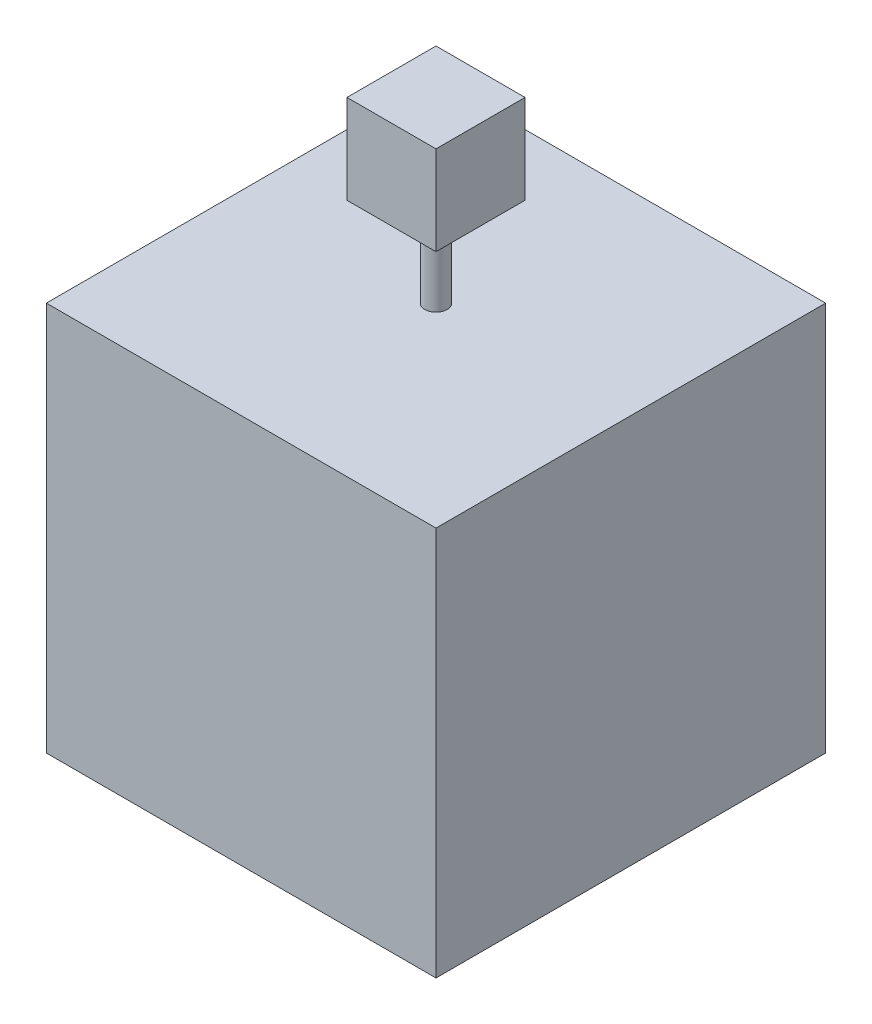
from build123d import *

# Parameters (mm, degrees)
ESQUISSE1_W      = 350
ESQUISSE1_H      = 350
EXTRUSION1_DEPTH = 350
ESQUISSE2_R      = 10
EXTRUSION2_DEPTH = 80
ESQUISSE3_W      = 80
ESQUISSE3_H      = 80
EXTRUSION3_DEPTH = 80


with BuildPart() as part:
    # Esquisse1 → Extrusion1 (new body)
    with BuildSketch(Plane(origin=(0, 0, 0), x_dir=(1, 0, 0), z_dir=(0, 1, 0))):
        with Locations((175, 175)):
            Rectangle(ESQUISSE1_W, ESQUISSE1_H)
    extrude(amount=EXTRUSION1_DEPTH)

    # Esquisse2 → Extrusion2 (add)
    with BuildSketch(Plane(origin=(0, 350, 0), x_dir=(1, 0, 0), z_dir=(0, 1, 0))):
        with Locations((175, 175)):
            Circle(ESQUISSE2_R)
    extrude(amount=EXTRUSION2_DEPTH)

    # Esquisse3 → Extrusion3 (add)
    with BuildSketch(Plane(origin=(0, 430, 0), x_dir=(1, 0, 0), z_dir=(0, 1, 0))):
        with Locations((175, 175)):
            Rectangle(ESQUISSE3_W, ESQUISSE3_H)
    extrude(amount=EXTRUSION3_DEPTH)


solid = part.part
